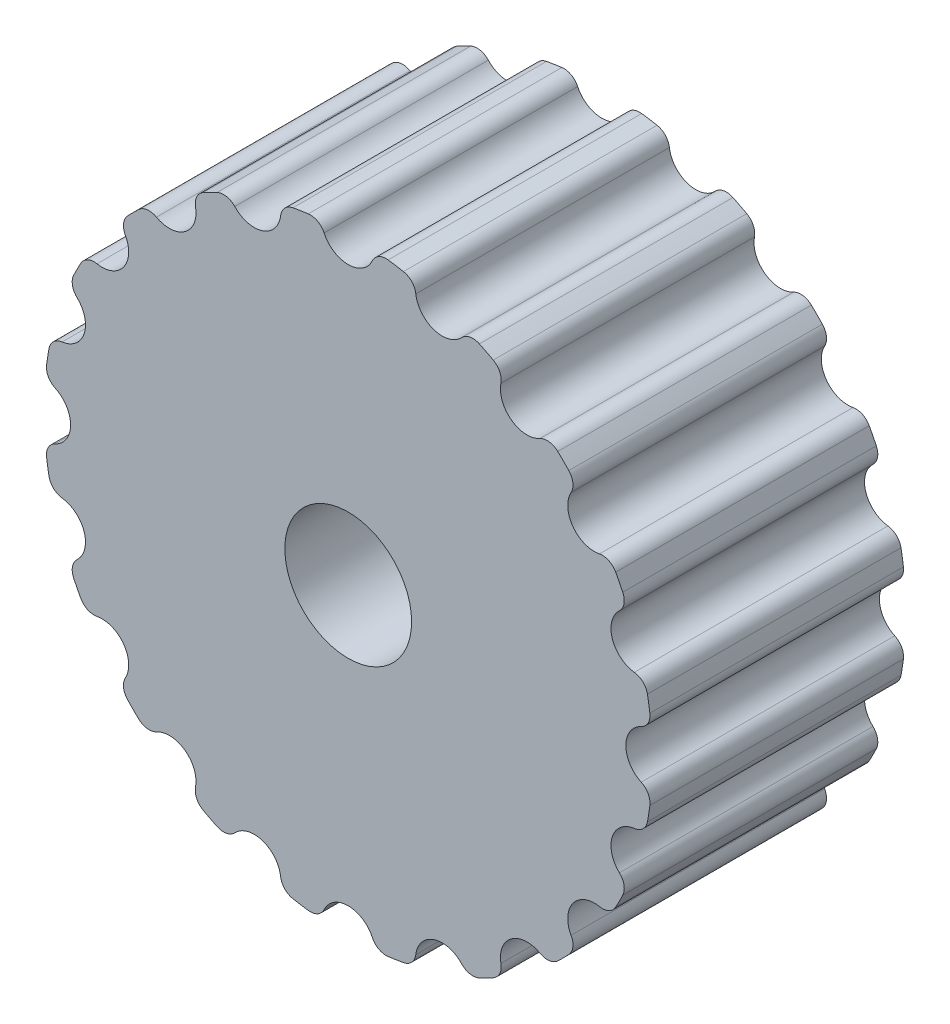
from build123d import *

# Parameters (mm, degrees)
SKETCH1_R           = 12
SKETCH1_R_2         = 2.5
BOSS_EXTRUDE1_DEPTH = 10
SKETCH2_R           = 1.05
CUT_EXTRUDE1_DEPTH  = 10
FILLET1_R           = 0.6


with BuildPart() as part:
    # Sketch1 → Boss-Extrude1 (new body)
    with BuildSketch(Plane.XY):
        Circle(SKETCH1_R)
        Circle(SKETCH1_R_2, mode=Mode.SUBTRACT)
    extrude(amount=BOSS_EXTRUDE1_DEPTH)

    # Sketch2 → Cut-Extrude1 (cut)
    with BuildSketch(Plane.XY.offset(10)):
        with Locations((0, 12)):
            Circle(SKETCH2_R)
        with Locations((3.708203932, 11.412678196)):
            Circle(SKETCH2_R)
        with Locations((7.053423028, 9.708203932)):
            Circle(SKETCH2_R)
        with Locations((9.708203932, 7.053423028)):
            Circle(SKETCH2_R)
        with Locations((11.412678196, 3.708203932)):
            Circle(SKETCH2_R)
        with Locations((12, 0)):
            Circle(SKETCH2_R)
        with Locations((11.412678196, -3.708203932)):
            Circle(SKETCH2_R)
        with Locations((9.708203932, -7.053423028)):
            Circle(SKETCH2_R)
        with Locations((7.053423028, -9.708203932)):
            Circle(SKETCH2_R)
        with Locations((3.708203933, -11.412678196)):
            Circle(SKETCH2_R)
        with Locations((0, -12)):
            Circle(SKETCH2_R)
        with Locations((-3.708203932, -11.412678196)):
            Circle(SKETCH2_R)
        with Locations((-7.053423028, -9.708203932)):
            Circle(SKETCH2_R)
        with Locations((-9.708203932, -7.053423028)):
            Circle(SKETCH2_R)
        with Locations((-11.412678196, -3.708203932)):
            Circle(SKETCH2_R)
        with Locations((-12, 0)):
            Circle(SKETCH2_R)
        with Locations((-11.412678196, 3.708203932)):
            Circle(SKETCH2_R)
        with Locations((-9.708203932, 7.053423028)):
            Circle(SKETCH2_R)
        with Locations((-7.053423028, 9.708203932)):
            Circle(SKETCH2_R)
        with Locations((-3.708203932, 11.412678196)):
            Circle(SKETCH2_R)
    extrude(amount=-CUT_EXTRUDE1_DEPTH, mode=Mode.SUBTRACT)

    # Fillet1
    fillet1_edges = [part.edges().sort_by_distance(p)[0] for p in [
        (-1.048994636, 11.9540625, 5),
        (1.048994636, 11.9540625, 5),
        (-4.691661648, 11.044831867, 5),
        (-2.69635528, 11.693146206, 5),
        (-7.87507613, 9.054456138, 5),
        (-6.177767155, 10.287623291, 5),
        (-10.287623291, 6.177767155, 5),
        (-9.054456138, 7.87507613, 5),
        (2.69635528, 11.693146206, 5),
        (4.691661648, 11.044831867, 5),
        (6.177767155, 10.287623291, 5),
        (7.87507613, 9.054456138, 5),
        (9.054456138, 7.87507613, 5),
        (10.287623291, 6.177767155, 5),
        (11.044831867, 4.691661648, 5),
        (11.693146206, 2.69635528, 5),
        (11.9540625, 1.048994636, 5),
        (11.9540625, -1.048994636, 5),
        (11.693146206, -2.69635528, 5),
        (11.044831867, -4.691661648, 5),
        (10.287623291, -6.177767155, 5),
        (9.054456138, -7.87507613, 5),
        (7.87507613, -9.054456138, 5),
        (6.177767155, -10.287623291, 5),
        (4.691661648, -11.044831867, 5),
        (2.69635528, -11.693146206, 5),
        (1.048994636, -11.9540625, 5),
        (-1.048994636, -11.9540625, 5),
        (-2.69635528, -11.693146206, 5),
        (-4.691661648, -11.044831867, 5),
        (-6.177767155, -10.287623291, 5),
        (-7.87507613, -9.054456138, 5),
        (-9.054456138, -7.87507613, 5),
        (-10.287623291, -6.177767155, 5),
        (-11.044831867, -4.691661648, 5),
        (-11.693146206, -2.69635528, 5),
        (-11.9540625, -1.048994636, 5),
        (-11.9540625, 1.048994636, 5),
        (-11.693146206, 2.69635528, 5),
        (-11.044831867, 4.691661648, 5),
    ]]
    fillet(fillet1_edges, radius=FILLET1_R)


solid = part.part
